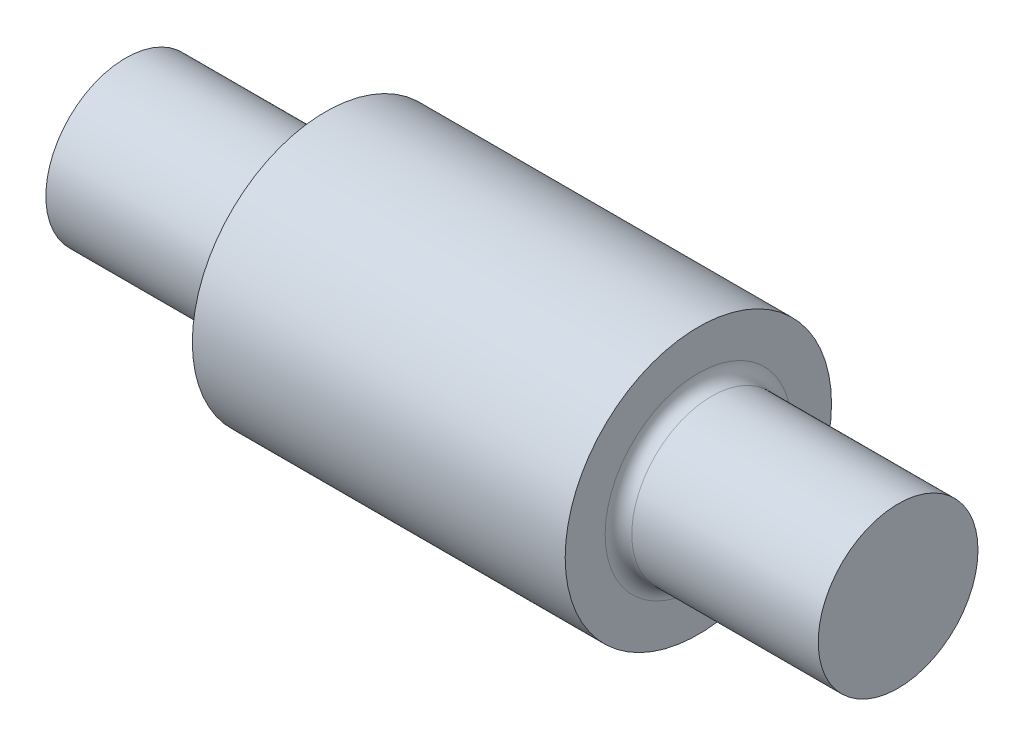
from build123d import *

# Parameters (mm, degrees)
SKETCH1_R           = 10
BOSS_EXTRUDE1_DEPTH = 14
SKETCH_1_R          = 6
EXTRUDE_1_DEPTH     = 15
FILLET_1_R          = 1


with BuildPart() as part:
    # Sketch1 → Boss-Extrude1 (new body, symmetric)
    with BuildSketch(Plane(origin=(0, 0, 0), x_dir=(0, 0, -1), z_dir=(1, 0, 0))):
        Circle(SKETCH1_R)
    extrude(amount=BOSS_EXTRUDE1_DEPTH, both=True)

    # 草图1 → 凸台-拉伸1 (add)
    with BuildSketch(Plane(origin=(14, 0, 0), x_dir=(0, 0, -1), z_dir=(1, 0, 0))):
        Circle(SKETCH_1_R)
    extrude_1 = extrude(amount=EXTRUDE_1_DEPTH)

    # 镜向1: 凸台-拉伸1 across plane
    add(extrude_1.mirror(Plane(origin=(0, 0, 0), x_dir=(0, 0, 1), z_dir=(1, 0, 0))))

    # 圆角1
    fillet_1_edges = [part.edges().sort_by_distance(p)[0] for p in [
        (-14, 0, 6),
        (14, 0, 6),
    ]]
    fillet(fillet_1_edges, radius=FILLET_1_R)


solid = part.part
